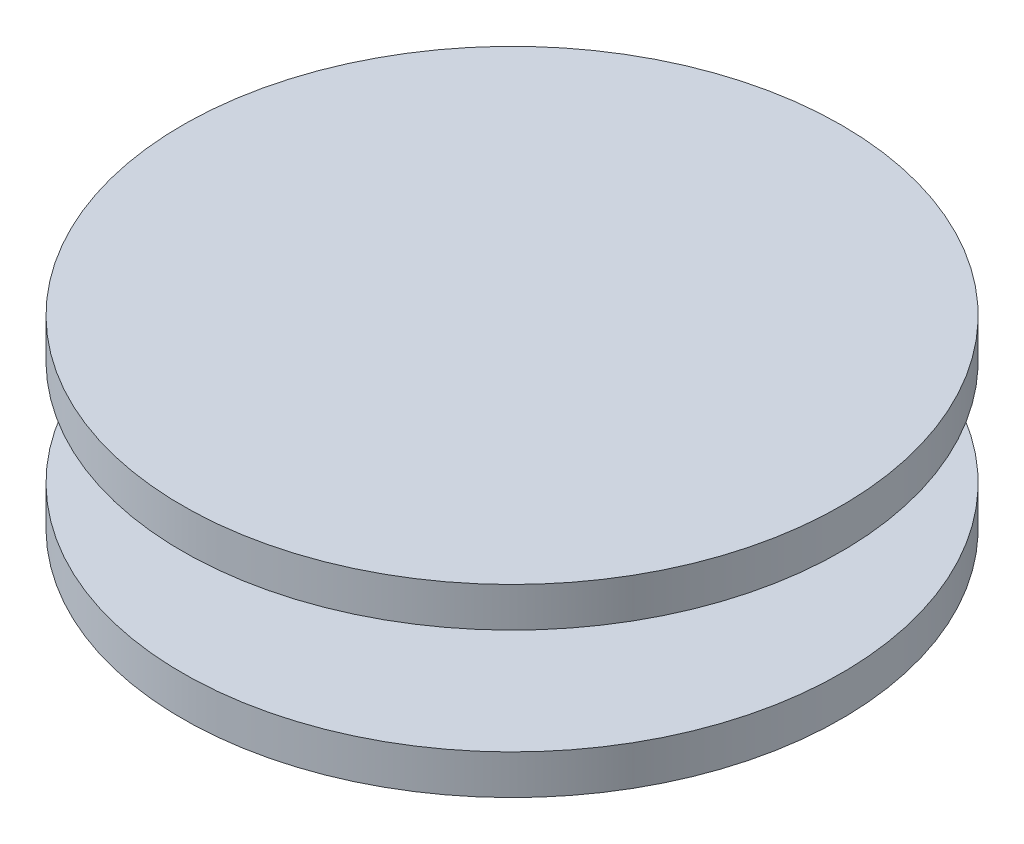
from build123d import *


with BuildPart() as part:
    # ｽｹｯﾁ1 → 回転1 (revolve)
    with BuildSketch(Plane.XY):
        Polygon((0, 0), (25, 0), (25, 3), (10, 3), (10, 11), (25, 11), (25, 14), (0, 14), align=None)
    revolve(axis=Axis((0, 0, 0), (0, 1, 0)))


solid = part.part
